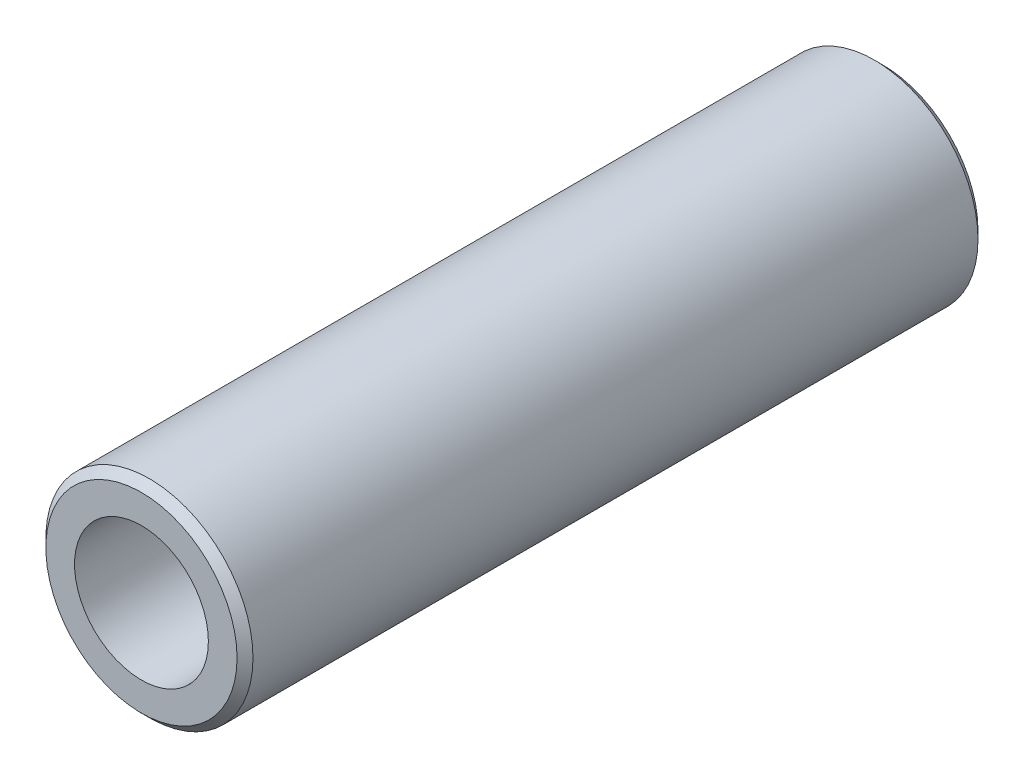
from build123d import *

# Parameters (mm, degrees)
SCHIZZO2_R                   = 6.5
SCHIZZO2_R_2                 = 4.2
ESTRUSIONE_ESTRUSIONE1_DEPTH = 46.5
SMUSSO1_SIZE                 = 0.5


with BuildPart() as part:
    # Schizzo2 → Estrusione-Estrusione1 (new body)
    with BuildSketch(Plane.XY):
        Circle(SCHIZZO2_R)
        Circle(SCHIZZO2_R_2, mode=Mode.SUBTRACT)
    extrude(amount=ESTRUSIONE_ESTRUSIONE1_DEPTH)

    # Smusso1
    smusso1_edges = [part.edges().sort_by_distance(p)[0] for p in [
        (-6.5, 0, 0),
        (-6.5, 0, 46.5),
    ]]
    chamfer(smusso1_edges, length=SMUSSO1_SIZE)


solid = part.part
